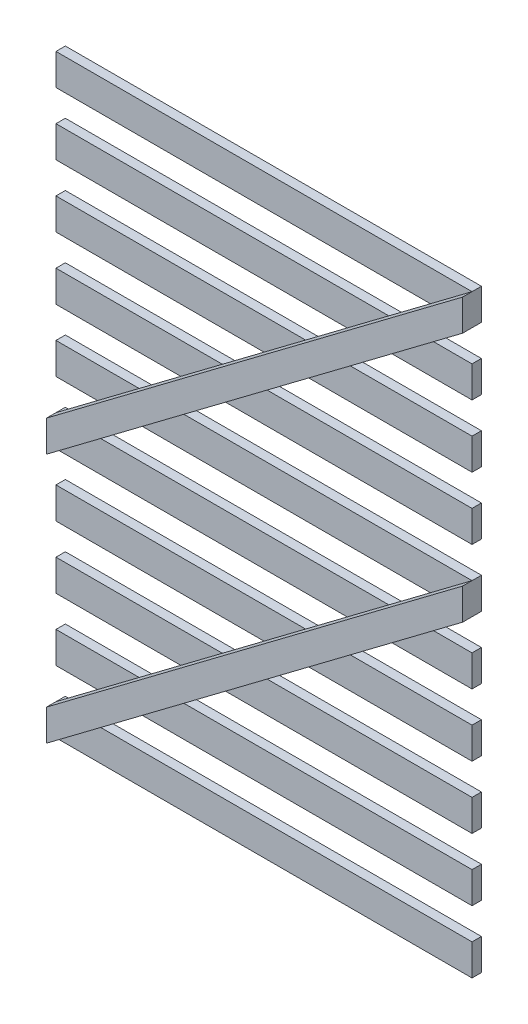
from build123d import *

# Parameters (mm, degrees)
SKETCH1_W              = 1330
SKETCH1_H              = 100
BOSS_EXTRUDE1_DEPTH    = 30
BOSS_EXTRUDE1_2_DEPTH  = 30
BOSS_EXTRUDE1_3_DEPTH  = 30
BOSS_EXTRUDE1_4_DEPTH  = 30
BOSS_EXTRUDE1_5_DEPTH  = 30
BOSS_EXTRUDE1_6_DEPTH  = 30
BOSS_EXTRUDE1_7_DEPTH  = 30
BOSS_EXTRUDE1_8_DEPTH  = 30
BOSS_EXTRUDE1_9_DEPTH  = 30
BOSS_EXTRUDE1_10_DEPTH = 30
BOSS_EXTRUDE2_DEPTH    = 30


with BuildPart() as part:
    # Sketch1 → Boss-Extrude1 (new body)
    with BuildSketch(Plane.XY):
        with Locations((665, -500)):
            Rectangle(SKETCH1_W, SKETCH1_H)
    extrude(amount=BOSS_EXTRUDE1_DEPTH)



with BuildPart() as body_2:
    # Sketch1 → Boss-Extrude1 2 (new body)
    with BuildSketch(Plane.XY):
        with Locations((665, -700)):
            Rectangle(SKETCH1_W, SKETCH1_H)
    extrude(amount=BOSS_EXTRUDE1_2_DEPTH)


with BuildPart() as body_3:
    # Sketch1 → Boss-Extrude1 3 (new body)
    with BuildSketch(Plane.XY):
        with Locations((665, -900)):
            Rectangle(SKETCH1_W, SKETCH1_H)
    extrude(amount=BOSS_EXTRUDE1_3_DEPTH)


with BuildPart() as body_4:
    # Sketch1 → Boss-Extrude1 4 (new body)
    with BuildSketch(Plane.XY):
        with Locations((665, -1100)):
            Rectangle(SKETCH1_W, SKETCH1_H)
    extrude(amount=BOSS_EXTRUDE1_4_DEPTH)


with BuildPart() as body_5:
    # Sketch1 → Boss-Extrude1 5 (new body)
    with BuildSketch(Plane.XY):
        with Locations((665, -1300)):
            Rectangle(SKETCH1_W, SKETCH1_H)
    extrude(amount=BOSS_EXTRUDE1_5_DEPTH)


with BuildPart() as body_6:
    # Sketch1 → Boss-Extrude1 6 (new body)
    with BuildSketch(Plane.XY):
        with Locations((665, -1900)):
            Rectangle(SKETCH1_W, SKETCH1_H)
    extrude(amount=BOSS_EXTRUDE1_6_DEPTH)


with BuildPart() as body_7:
    # Sketch1 → Boss-Extrude1 7 (new body)
    with BuildSketch(Plane.XY):
        with Locations((665, -100)):
            Rectangle(SKETCH1_W, SKETCH1_H)
    extrude(amount=BOSS_EXTRUDE1_7_DEPTH)


with BuildPart() as body_8:
    # Sketch1 → Boss-Extrude1 8 (new body)
    with BuildSketch(Plane.XY):
        with Locations((665, -300)):
            Rectangle(SKETCH1_W, SKETCH1_H)
    extrude(amount=BOSS_EXTRUDE1_8_DEPTH)


with BuildPart() as body_9:
    # Sketch1 → Boss-Extrude1 9 (new body)
    with BuildSketch(Plane.XY):
        with Locations((665, -1500)):
            Rectangle(SKETCH1_W, SKETCH1_H)
    extrude(amount=BOSS_EXTRUDE1_9_DEPTH)


with BuildPart() as body_10:
    # Sketch1 → Boss-Extrude1 10 (new body)
    with BuildSketch(Plane.XY):
        with Locations((665, -1700)):
            Rectangle(SKETCH1_W, SKETCH1_H)
    extrude(amount=BOSS_EXTRUDE1_10_DEPTH)


with BuildPart() as part_1:
    add(part.part)

    add(body_2.part)  # Boss-Extrude2 merges body 2

    add(body_3.part)  # Boss-Extrude2 merges body 3

    add(body_4.part)  # Boss-Extrude2 merges body 4

    add(body_5.part)  # Boss-Extrude2 merges body 5

    add(body_6.part)  # Boss-Extrude2 merges body 6

    add(body_7.part)  # Boss-Extrude2 merges body 7

    add(body_8.part)  # Boss-Extrude2 merges body 8

    add(body_9.part)  # Boss-Extrude2 merges body 9

    add(body_10.part)  # Boss-Extrude2 merges body 10
    # Sketch2 → Boss-Extrude2 (add)
    with BuildSketch(Plane.XY.offset(30)):
        Polygon((1330, -50), (0, -1050), (0, -1150), (1330, -150), align=None)
        Polygon((1330, -850), (0, -1850), (0, -1950), (1330, -950), align=None)
    extrude(amount=BOSS_EXTRUDE2_DEPTH)


solid = part_1.part
